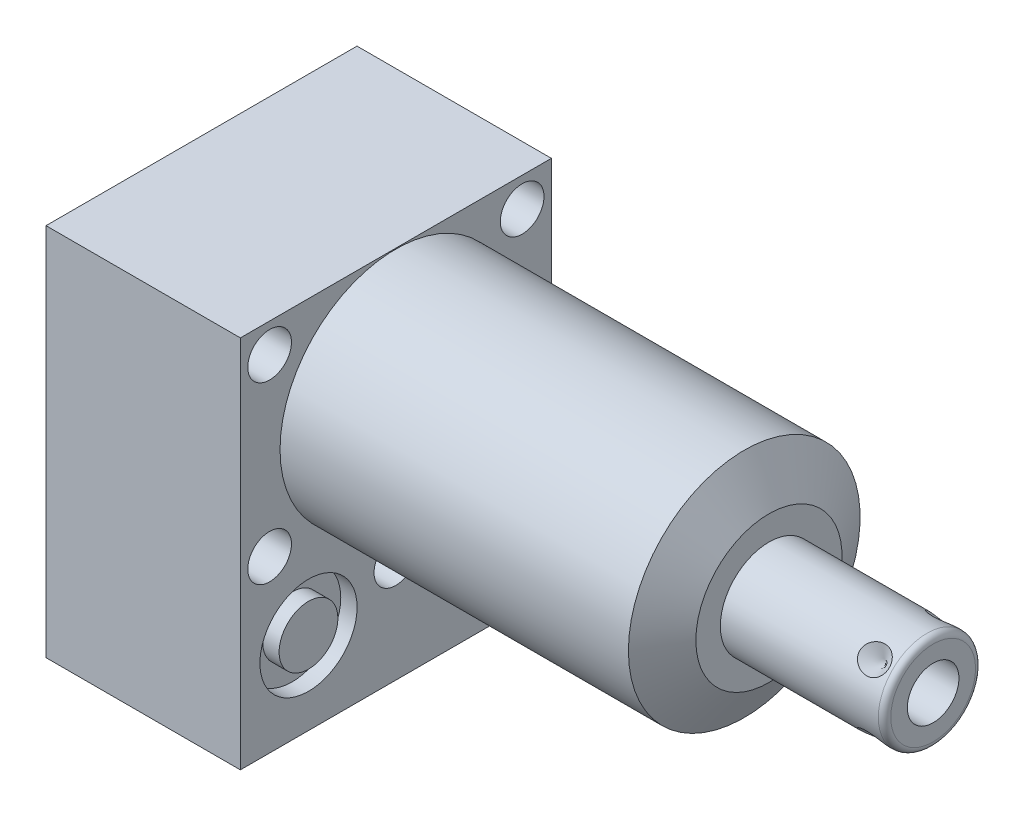
from build123d import *

# Parameters (mm, degrees)
SKETCH1_W           = 50.8
SKETCH1_H           = 61.1124
EXTRUDE1_DEPTH      = 60.9346
EXTRUDE1_DEPTH_BACK = 31.75
CUT_EXTRUDE1_REACH  = 62.935
SKETCH2_W           = 50.8
SKETCH2_H           = 61.1124
SKETCH2_R           = 18.923
SKETCH18_R          = 7.9375
CUT_EXTRUDE2_DEPTH  = 2.667
SKETCH19_R          = 7.9375
CUT_EXTRUDE3_DEPTH  = 2.667
SKETCH20_R          = 9.525
CUT_EXTRUDE4_DEPTH  = 0.254
SKETCH12_R          = 6.4389
EXTRUDE2_DEPTH      = 1.651
EXTRUDE3_START      = -2.667
SKETCH13_R          = 4.8006
EXTRUDE3_DEPTH      = 2.667
SKETCH14_R          = 1.7653
SKETCH15_R          = 1.7653
CIRPATTERN1_COUNT   = 4
SKETCH21_W          = 3.5687
SKETCH21_H          = 31.75
HOLE1_AT_2_COUNT    = 2
HOLE1_AT_2_PITCH    = 44.445239059
HOLE1_AT_3_COUNT    = 2
HOLE1_AT_3_PITCH    = 28.5496
HOLE1_AT_4_COUNT    = 2
HOLE1_AT_4_PITCH    = 41.2496
HOLE1_AT_5_COUNT    = 2
HOLE1_AT_5_PITCH    = 50.165816652
SKETCH24_R          = 4.8006
EXTRUDE4_DEPTH      = 2.667


with BuildPart() as part:
    # Sketch1 → Extrude1 (new body, two sides)
    with BuildSketch(Plane(origin=(0, 0, 0), x_dir=(0, 0, -1), z_dir=(1, 0, 0))) as extrude1_sk:
        with Locations((0, -11.5062)):
            Rectangle(SKETCH1_W, SKETCH1_H)
    extrude(amount=EXTRUDE1_DEPTH)
    extrude(extrude1_sk.sketch, amount=-EXTRUDE1_DEPTH_BACK)

    # Sketch2 → Cut-Extrude1 (cut, up to next)
    with BuildSketch(Plane(origin=(0, 0, 0), x_dir=(0, 0, -1), z_dir=(1, 0, 0)), mode=Mode.PRIVATE) as cut_extrude1_sk1:
        with Locations((0, -11.5062)):
            Rectangle(SKETCH2_W, SKETCH2_H)
        Circle(SKETCH2_R, mode=Mode.SUBTRACT)
    cut_extrude1_tool1 = extrude(cut_extrude1_sk1.sketch, amount=CUT_EXTRUDE1_REACH, mode=Mode.PRIVATE) & part.part
    add(cut_extrude1_tool1.solids().sort_by_distance((0, 18.970531, 0))[0], mode=Mode.SUBTRACT)

    # Sketch3 → Cut-Revolve1 (revolve, cut)
    with BuildSketch(Plane.XY, mode=Mode.PRIVATE) as cut_revolve1_sk:
        Polygon((56.90180837, 18.923), (60.9346, 11.938), (60.9346, 18.923), align=None)
    revolve(cut_revolve1_sk.sketch.rotate(Axis((56.700168788, 0, 0), (1, 0, 0)), 90), axis=Axis((56.700168788, 0, 0), (1, 0, 0)), mode=Mode.SUBTRACT)  # turned: the seam where the file's is

    # S2D0002 → Cut-Revolve2 (revolve, cut)
    with BuildSketch(Plane(origin=(-29.083, -28.575, 14.2748), x_dir=(0, 1, 0), z_dir=(0, 0, 1)), mode=Mode.PRIVATE) as cut_revolve2_sk:
        Polygon((0, 0), (4.5466, 0), (4.106586662, -2.0701), (3.4544, -2.722286662), (3.4544, -13.97), (0, -13.97), align=None)
    revolve(cut_revolve2_sk.sketch.rotate(Axis((-14.4145, -28.575, 14.2748), (-1, 0, 0)), 90), axis=Axis((-14.4145, -28.575, 14.2748), (-1, 0, 0)), mode=Mode.SUBTRACT)  # turned: the seam where the file's is

    # Sketch5 → Cut-Revolve3 (revolve, cut)
    with BuildSketch(Plane(origin=(-29.083, -28.575, -14.2748), x_dir=(0, 1, 0), z_dir=(0, 0, 1)), mode=Mode.PRIVATE) as cut_revolve3_sk:
        Polygon((0, 0), (4.5466, 0), (4.106586662, -2.0701), (3.4544, -2.722286662), (3.4544, -13.97), (0, -13.97), align=None)
    revolve(cut_revolve3_sk.sketch.rotate(Axis((-14.4145, -28.575, -14.2748), (-1, 0, 0)), 90), axis=Axis((-14.4145, -28.575, -14.2748), (-1, 0, 0)), mode=Mode.SUBTRACT)  # turned: the seam where the file's is

    # Sketch6 → Cut-Revolve4 (revolve, cut)
    with BuildSketch(Plane(origin=(-2.667, -28.575, 14.2748), x_dir=(0, -1, 0), z_dir=(0, 0, 1)), mode=Mode.PRIVATE) as cut_revolve4_sk:
        Polygon((0, 0), (4.5466, 0), (4.106586662, -2.0701), (3.4544, -2.722286662), (3.4544, -12.192), (0, -12.192), align=None)
    revolve(cut_revolve4_sk.sketch.rotate(Axis((-15.4686, -28.575, 14.2748), (1, 0, 0)), 90), axis=Axis((-15.4686, -28.575, 14.2748), (1, 0, 0)), mode=Mode.SUBTRACT)  # turned: the seam where the file's is

    # Sketch7 → Cut-Revolve5 (revolve, cut)
    with BuildSketch(Plane(origin=(-2.667, -28.575, -14.2748), x_dir=(0, -1, 0), z_dir=(0, 0, 1)), mode=Mode.PRIVATE) as cut_revolve5_sk:
        Polygon((0, 0), (4.5466, 0), (4.106586662, -2.0701), (3.4544, -2.722286662), (3.4544, -12.192), (0, -12.192), align=None)
    revolve(cut_revolve5_sk.sketch.rotate(Axis((-15.4686, -28.575, -14.2748), (1, 0, 0)), 90), axis=Axis((-15.4686, -28.575, -14.2748), (1, 0, 0)), mode=Mode.SUBTRACT)  # turned: the seam where the file's is

    # Sketch18 → Cut-Extrude2 (cut)
    with BuildSketch(Plane.ZY.offset(31.75)):
        with Locations((-14.2748, -28.575)):
            Circle(SKETCH18_R)
        with Locations((14.2748, -28.575)):
            Circle(SKETCH18_R)
    extrude(amount=-CUT_EXTRUDE2_DEPTH, mode=Mode.SUBTRACT)

    # Sketch19 → Cut-Extrude3 (cut)
    with BuildSketch(Plane(origin=(0, 0, 0), x_dir=(0, 0, -1), z_dir=(1, 0, 0))):
        with Locations((-14.2748, -28.575)):
            Circle(SKETCH19_R)
        with Locations((14.2748, -28.575)):
            Circle(SKETCH19_R)
    extrude(amount=-CUT_EXTRUDE3_DEPTH, mode=Mode.SUBTRACT)

    # Sketch8 → Cut-Revolve6 (revolve, cut)
    with BuildSketch(Plane(origin=(-15.875, -43.688, 14.2748), x_dir=(-1, 0, 0), z_dir=(0, 0, 1)), mode=Mode.PRIVATE) as cut_revolve6_sk:
        Polygon((0, -1.8796), (6.1849, -1.8796), (5.642306865, -4.4323), (4.9784, -5.096206865), (4.9784, -20.9296), (0, -20.9296), align=None)
    revolve(cut_revolve6_sk.sketch.rotate(Axis((-15.875, -17.018, 14.2748), (0, -1, 0)), 270), axis=Axis((-15.875, -17.018, 14.2748), (0, -1, 0)), mode=Mode.SUBTRACT)  # turned: the seam where the file's is

    # Sketch9 → Cut-Revolve7 (revolve, cut)
    with BuildSketch(Plane(origin=(-15.875, -43.688, -14.2748), x_dir=(-1, 0, 0), z_dir=(0, 0, 1)), mode=Mode.PRIVATE) as cut_revolve7_sk:
        Polygon((0, -1.8796), (6.1849, -1.8796), (5.642306865, -4.4323), (4.9784, -5.096206865), (4.9784, -20.9296), (0, -20.9296), align=None)
    revolve(cut_revolve7_sk.sketch.rotate(Axis((-15.875, -17.018, -14.2748), (0, -1, 0)), 270), axis=Axis((-15.875, -17.018, -14.2748), (0, -1, 0)), mode=Mode.SUBTRACT)  # turned: the seam where the file's is

    # Sketch20 → Cut-Extrude4 (cut)
    with BuildSketch(Plane.XZ.offset(42.0624)):
        with Locations(Location((-15.875, 14.2748, 0), (0, 0, 270))):  # turned: the seam where the file's is
            Circle(SKETCH20_R)
        with Locations(Location((-15.875, -14.2748, 0), (0, 0, 270))):  # turned: the seam where the file's is
            Circle(SKETCH20_R)
    extrude(amount=-CUT_EXTRUDE4_DEPTH, mode=Mode.SUBTRACT)

    # Sketch10 → Revolve1 (revolve)
    with BuildSketch(Plane.XY, mode=Mode.PRIVATE) as revolve1_sk:
        with BuildLine():
            Line((60.9346, 0), (60.9346, 7.9375))
            Line((60.9346, 7.9375), (86.741, 7.9375))
            ThreePointArc((86.741, 7.9375), (87.45942049, 7.63992049), (87.757, 6.9215))
            Line((87.757, 6.9215), (87.757, 0))
            Line((87.757, 0), (60.9346, 0))
        make_face()
    revolve(revolve1_sk.sketch.rotate(Axis((59.59348, 0, 0), (1, 0, 0)), 90), axis=Axis((59.59348, 0, 0), (1, 0, 0)))  # turned: the seam where the file's is

    # S2D0001 → Cut-Revolve8 (revolve, cut)
    with BuildSketch(Plane(origin=(87.757, -4.2164, 0), x_dir=(0, -1, 0), z_dir=(0, 0, 1)), mode=Mode.PRIVATE) as cut_revolve8_sk:
        Polygon((0, 0), (0, -15.24), (-4.2164, -17.773468714), (-4.2164, 0), align=None)
    revolve(cut_revolve8_sk.sketch.rotate(Axis((62.891960697, 0, 0), (1, 0, 0)), 270), axis=Axis((62.891960697, 0, 0), (1, 0, 0)), mode=Mode.SUBTRACT)  # turned: the seam where the file's is

    # Sketch12 → Extrude2 (add)
    with BuildSketch(Plane(origin=(-31.75, -41.8084, 0), x_dir=(0, 0, -1), z_dir=(0, -1, 0))):
        with Locations((-14.2748, 15.875)):
            Circle(SKETCH12_R)
    extrude(amount=EXTRUDE2_DEPTH)

    # Sketch13 → Extrude3 (add)
    with BuildSketch(Plane(origin=(0, 0, 0), x_dir=(0, 0, -1), z_dir=(1, 0, 0)).offset(EXTRUDE3_START)):
        with Locations((-14.2748, -28.575)):
            Circle(SKETCH13_R)
    extrude(amount=EXTRUDE3_DEPTH)

    # Sketch16 → Cut-Revolve9 (revolve, cut)
    with BuildSketch(Plane(origin=(83.7946, 5.612660076, -5.612660076), x_dir=(-1, 0, 0), z_dir=(0, -0.707106781, -0.707106781)), mode=Mode.PRIVATE) as cut_revolve9_sk:
        Polygon((0, 0), (2.413, 0), (0, -2.413), align=None)
    cut_revolve9 = revolve(cut_revolve9_sk.sketch.rotate(Axis((83.7946, 2.92180895, -2.92180895), (0, 0.707106781, -0.707106781)), 90), axis=Axis((83.7946, 2.92180895, -2.92180895), (0, 0.707106781, -0.707106781)), mode=Mode.SUBTRACT)  # turned: the seam where the file's is

    # CirPattern1: Cut-Revolve9 ×4 about axis
    cirpattern1_axis = Axis((60.9356, 0, 0), (-1, 0, 0))
    for i in range(1, CIRPATTERN1_COUNT):
        add(cut_revolve9.rotate(cirpattern1_axis, i * 360 / CIRPATTERN1_COUNT), mode=Mode.SUBTRACT)

    # Sketch21 → Hole1 (revolve, cut)
    with BuildSketch(Plane(origin=(0, 14.2748, 20.6248), x_dir=(0, 0, -1), z_dir=(0, 1, 0))):
        with Locations((1.78435, 15.875)):
            Rectangle(SKETCH21_W, SKETCH21_H)
    hole1 = revolve(axis=Axis((-110, 14.2748, 20.6248), (1, 0, 0)), mode=Mode.SUBTRACT)

    # Hole1 at 2: Hole1 ×2
    with Locations(*[Vector(0, -0.885809163, -0.464049703) * (i * HOLE1_AT_2_PITCH) for i in range(1, HOLE1_AT_2_COUNT)]):
        add(hole1, mode=Mode.SUBTRACT)

    # Hole1 at 3: Hole1 ×2
    with Locations(*[(0, -i * HOLE1_AT_3_PITCH, 0) for i in range(1, HOLE1_AT_3_COUNT)]):
        add(hole1, mode=Mode.SUBTRACT)

    # Hole1 at 4: Hole1 ×2
    with Locations(*[(0, 0, -i * HOLE1_AT_4_PITCH) for i in range(1, HOLE1_AT_4_COUNT)]):
        add(hole1, mode=Mode.SUBTRACT)

    # Hole1 at 5: Hole1 ×2
    with Locations(*[Vector(0, -0.569104659, -0.822265095) * (i * HOLE1_AT_5_PITCH) for i in range(1, HOLE1_AT_5_COUNT)]):
        add(hole1, mode=Mode.SUBTRACT)

    # Sketch24 → Extrude4 (add)
    with BuildSketch(Plane.ZY.offset(29.083)):
        with Locations(Location((14.2748, -28.575, 0), (0, 0, 180))):  # turned: the seam where the file's is
            Circle(SKETCH24_R)
    extrude(amount=EXTRUDE4_DEPTH)


with BuildPart() as body_2:
    # Sketch14 → Revolve2 (revolve)
    with BuildSketch(Plane(origin=(0, -28.575, -14.2748), x_dir=(0, 0, -1), z_dir=(0, -1, 0)), mode=Mode.PRIVATE) as revolve2_sk:
        with Locations((6.1722, -0.9017)):
            Circle(SKETCH14_R)
    revolve(revolve2_sk.sketch.rotate(Axis((-2.84353, -28.575, -14.2748), (1, 0, 0)), 180), axis=Axis((-2.84353, -28.575, -14.2748), (1, 0, 0)))  # turned: the seam where the file's is


with BuildPart() as body_3:
    # Sketch15 → Revolve3 (revolve)
    with BuildSketch(Plane(origin=(0, -28.575, -14.2748), x_dir=(0, 0, -1), z_dir=(0, -1, 0)), mode=Mode.PRIVATE) as revolve3_sk:
        with Locations((6.1722, -30.8483)):
            Circle(SKETCH15_R)
    revolve(revolve3_sk.sketch.rotate(Axis((-32.79013, -28.575, -14.2748), (1, 0, 0)), 180), axis=Axis((-32.79013, -28.575, -14.2748), (1, 0, 0)))  # turned: the seam where the file's is


solid = Compound([part.part, body_2.part, body_3.part])
